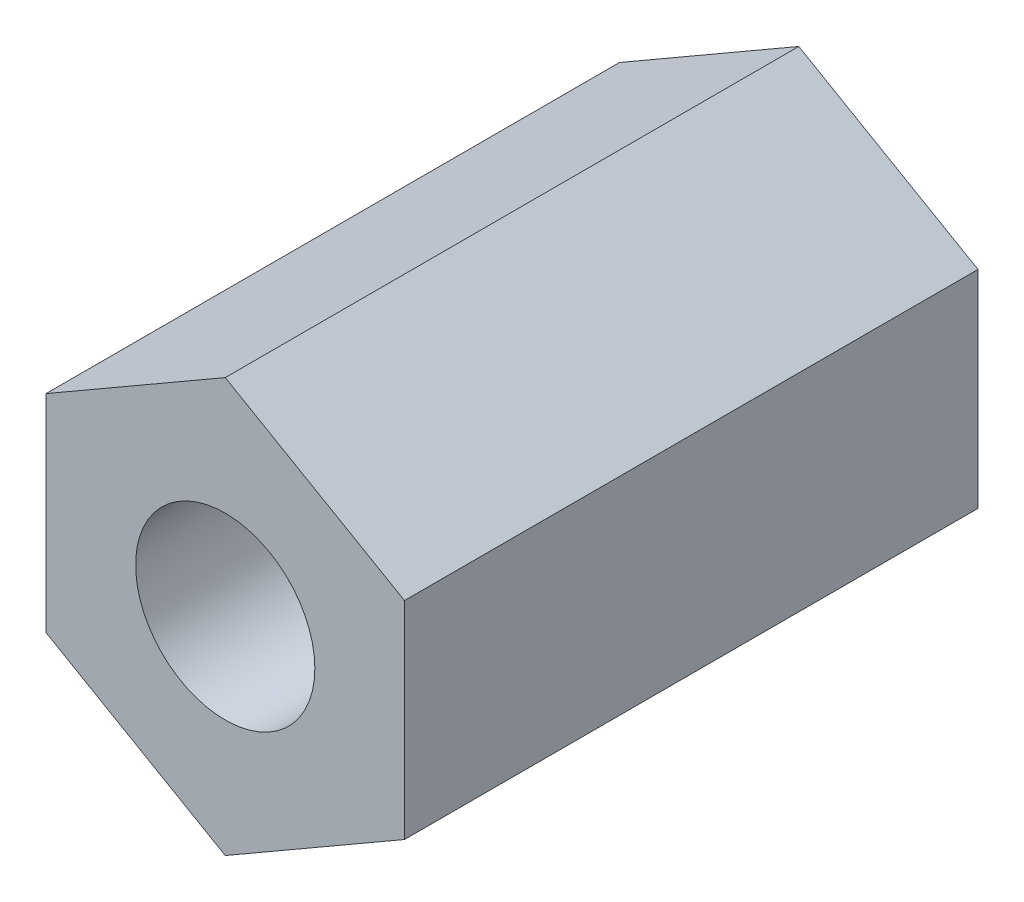
from build123d import *

# Parameters (mm, degrees)
BOSS_EXTRU_1_DEPTH                            = 8
TROU_POUR_TARAUDAGE_POUR_TROU_TARAUD_M3_D     = 2.5
TROU_POUR_TARAUDAGE_POUR_TROU_TARAUD_M3_DEPTH = 8


with BuildPart() as part:
    # Esquisse1 → Boss.-Extru.1 (new body)
    with BuildSketch(Plane.XY):
        Polygon((2.5, -1.443375673), (2.5, 1.443375673), (0, 2.886751346), (-2.5, 1.443375673), (-2.5, -1.443375673), (0, -2.886751346), align=None)
    extrude(amount=BOSS_EXTRU_1_DEPTH)

    # Trou pour taraudage pour trou taraudé M31
    with Locations(Plane.XY.offset(8)):
        with Locations((0, 0)):
            Hole(TROU_POUR_TARAUDAGE_POUR_TROU_TARAUD_M3_D / 2, depth=TROU_POUR_TARAUDAGE_POUR_TROU_TARAUD_M3_DEPTH)


solid = part.part
